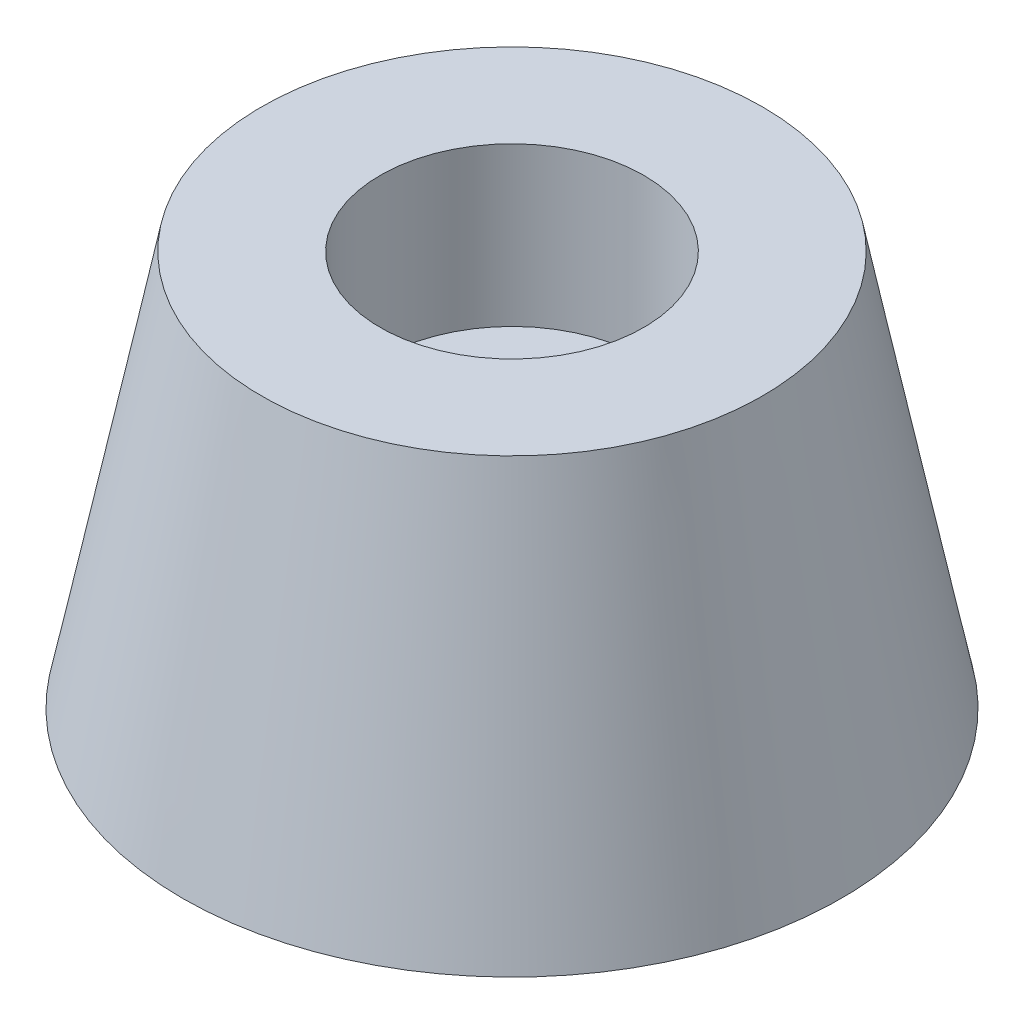
from build123d import *


with BuildPart() as part:
    # 草图1 → 旋转1 (revolve)
    with BuildSketch(Plane.XY):
        Polygon((-9.5, 15), (-12.5, 0), (-2.5, 0), (-2.5, 9), (-5, 9), (-5, 15), align=None)
    revolve(axis=Axis((0, 0, 0), (0, 1, 0)))


solid = part.part
